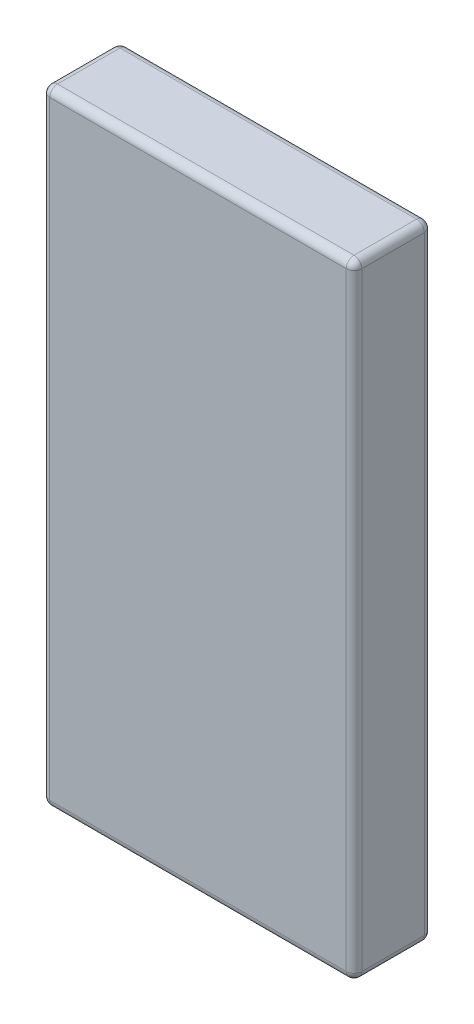
from build123d import *

# Parameters (mm, degrees)
SKETCH1_W           = 25.4
SKETCH1_H           = 50.8
BOSS_EXTRUDE1_DEPTH = 6.35
FILLET1_R           = 0.635


with BuildPart() as part:
    # Sketch1 → Boss-Extrude1 (new body)
    with BuildSketch(Plane.XY):
        Rectangle(SKETCH1_W, SKETCH1_H)
    extrude(amount=BOSS_EXTRUDE1_DEPTH)

    # Fillet1
    fillet1_edges = [part.edges().sort_by_distance(p)[0] for p in [
        (-12.7, 0, 6.35),
        (0, -25.4, 6.35),
        (12.7, 0, 6.35),
        (0, -25.4, 0),
        (-12.7, 0, 0),
        (0, 25.4, 0),
        (12.7, 0, 0),
        (12.7, -25.4, 3.175),
        (-12.7, -25.4, 3.175),
        (-12.7, 25.4, 3.175),
        (12.7, 25.4, 3.175),
        (0, 25.4, 6.35),
    ]]
    fillet(fillet1_edges, radius=FILLET1_R)


solid = part.part
